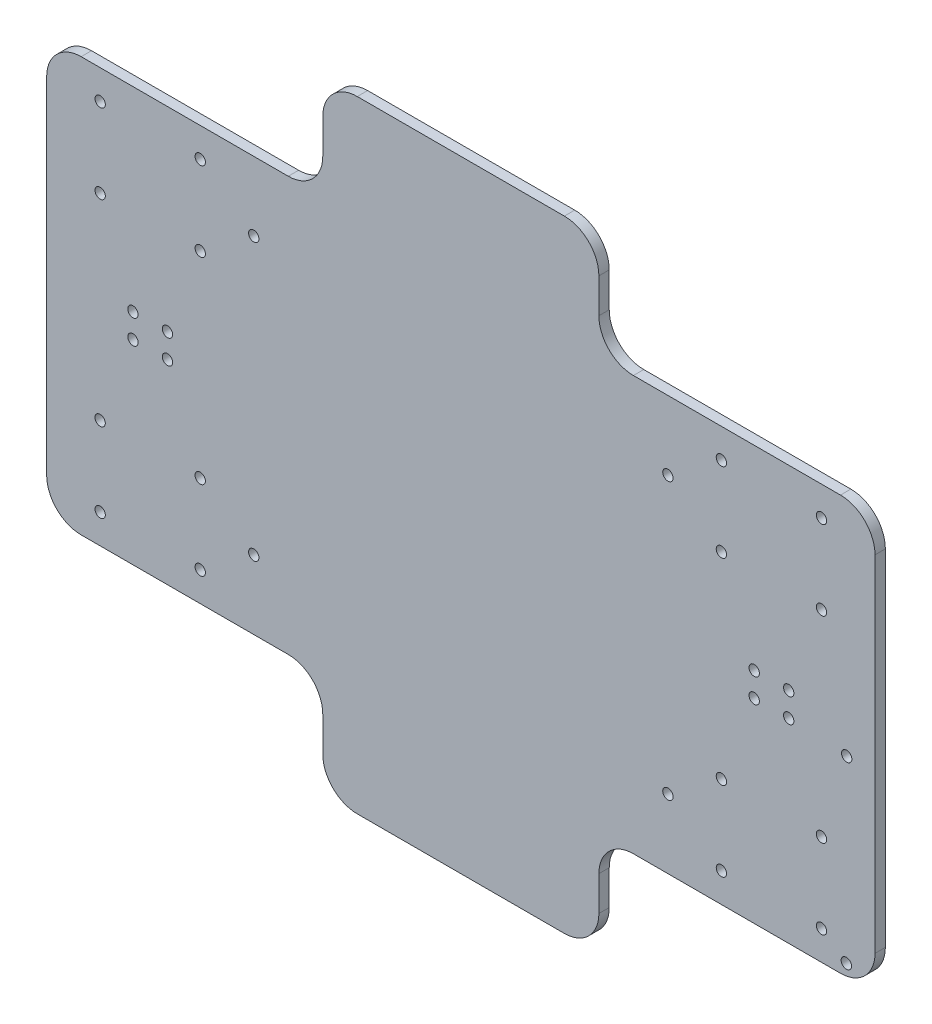
from build123d import *

# Parameters (mm, degrees)
SKETCH_1_R          = 1.5
EXTRUDE_1_DEPTH     = 3
FILLET_1_R          = 10
SKETCH_2_R          = 1.5
CUT_EXTRUDE_1_DEPTH = 10


with BuildPart() as part:
    # 草圖1 → 填料-伸長1 (new body)
    with BuildSketch(Plane.XY):
        Polygon((80, 0), (80, 30), (0, 30), (0, 150), (80, 150), (80, 180), (160, 180), (160, 150), (240, 150), (240, 30), (160, 30), (160, 0), align=None)
        with Locations((15.5, 61.5)):
            Circle(SKETCH_1_R, mode=Mode.SUBTRACT)
        with Locations((44.5, 61.5)):
            Circle(SKETCH_1_R, mode=Mode.SUBTRACT)
        with Locations((44.5, 38.5)):
            Circle(SKETCH_1_R, mode=Mode.SUBTRACT)
        with Locations((15.5, 38.5)):
            Circle(SKETCH_1_R, mode=Mode.SUBTRACT)
        with Locations((44.5, 141.5)):
            Circle(SKETCH_1_R, mode=Mode.SUBTRACT)
        with Locations((15.5, 141.5)):
            Circle(SKETCH_1_R, mode=Mode.SUBTRACT)
        with Locations((15.5, 118.5)):
            Circle(SKETCH_1_R, mode=Mode.SUBTRACT)
        with Locations((44.5, 118.5)):
            Circle(SKETCH_1_R, mode=Mode.SUBTRACT)
        with Locations((35, 86.5)):
            Circle(SKETCH_1_R, mode=Mode.SUBTRACT)
        with Locations((25, 86.5)):
            Circle(SKETCH_1_R, mode=Mode.SUBTRACT)
        with Locations((60, 50)):
            Circle(SKETCH_1_R, mode=Mode.SUBTRACT)
        with Locations((25, 93.5)):
            Circle(SKETCH_1_R, mode=Mode.SUBTRACT)
        with Locations((35, 93.5)):
            Circle(SKETCH_1_R, mode=Mode.SUBTRACT)
        with Locations((60, 130)):
            Circle(SKETCH_1_R, mode=Mode.SUBTRACT)
        with Locations((180, 130)):
            Circle(SKETCH_1_R, mode=Mode.SUBTRACT)
        with Locations((205, 93.5)):
            Circle(SKETCH_1_R, mode=Mode.SUBTRACT)
        with Locations((215, 93.5)):
            Circle(SKETCH_1_R, mode=Mode.SUBTRACT)
        with Locations((180, 50)):
            Circle(SKETCH_1_R, mode=Mode.SUBTRACT)
        with Locations((215, 86.5)):
            Circle(SKETCH_1_R, mode=Mode.SUBTRACT)
        with Locations((205, 86.5)):
            Circle(SKETCH_1_R, mode=Mode.SUBTRACT)
        with Locations((195.5, 118.5)):
            Circle(SKETCH_1_R, mode=Mode.SUBTRACT)
        with Locations((224.5, 118.5)):
            Circle(SKETCH_1_R, mode=Mode.SUBTRACT)
        with Locations((224.5, 141.5)):
            Circle(SKETCH_1_R, mode=Mode.SUBTRACT)
        with Locations((195.5, 141.5)):
            Circle(SKETCH_1_R, mode=Mode.SUBTRACT)
        with Locations((224.5, 38.5)):
            Circle(SKETCH_1_R, mode=Mode.SUBTRACT)
        with Locations((195.5, 38.5)):
            Circle(SKETCH_1_R, mode=Mode.SUBTRACT)
        with Locations((195.5, 61.5)):
            Circle(SKETCH_1_R, mode=Mode.SUBTRACT)
        with Locations((224.5, 61.5)):
            Circle(SKETCH_1_R, mode=Mode.SUBTRACT)
    extrude(amount=EXTRUDE_1_DEPTH)

    # 圓角1
    fillet_1_edges = [part.edges().sort_by_distance(p)[0] for p in [
        (80, 0, 1.5),
        (80, 30, 1.5),
        (0, 30, 1.5),
        (0, 150, 1.5),
        (80, 150, 1.5),
        (80, 180, 1.5),
        (160, 180, 1.5),
        (160, 150, 1.5),
        (240, 150, 1.5),
        (240, 30, 1.5),
        (160, 30, 1.5),
        (160, 0, 1.5),
    ]]
    fillet(fillet_1_edges, radius=FILLET_1_R)

    # 草圖2 → 除料-伸長1 (cut)
    with BuildSketch(Plane.XY.offset(3)):
        with Locations((231.801662433, 85.38)):
            Circle(SKETCH_2_R)
        with Locations((231.7, 33.38)):
            Circle(SKETCH_2_R)
    extrude(amount=-CUT_EXTRUDE_1_DEPTH, mode=Mode.SUBTRACT)


solid = part.part
